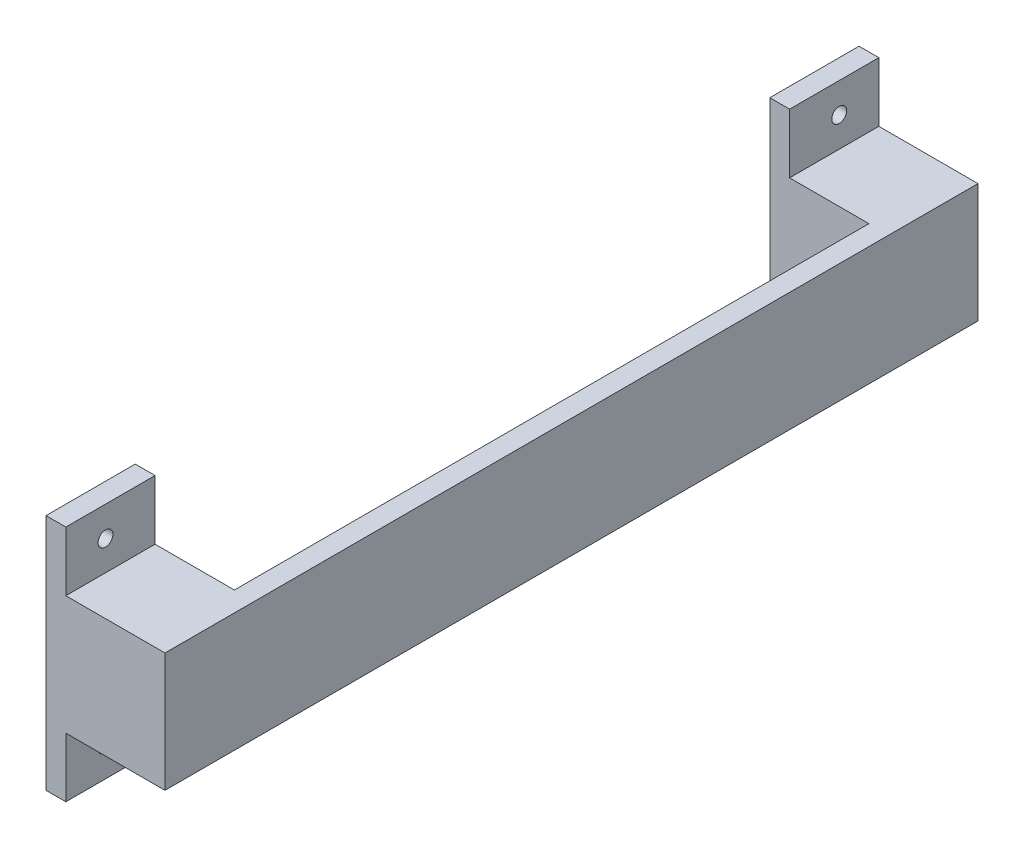
from build123d import *

# Parameters (mm, degrees)
SKETCH1_W           = 130.175
SKETCH1_H           = 19.05
BOSS_EXTRUDE1_DEPTH = 19.05
SKETCH2_W           = 3.175
SKETCH2_H           = 38.1
BOSS_EXTRUDE2_DEPTH = 130.175
SKETCH4_R           = 1.190625
CUT_EXTRUDE1_DEPTH  = 4.175
SKETCH5_W           = 15.875
SKETCH5_H           = 101.6
CUT_EXTRUDE2_DEPTH  = 39.1


with BuildPart() as part:
    # Sketch1 → Boss-Extrude1 (new body)
    with BuildSketch(Plane(origin=(0, 0, 0), x_dir=(0, 0, -1), z_dir=(1, 0, 0))):
        Rectangle(SKETCH1_W, SKETCH1_H)
    extrude(amount=BOSS_EXTRUDE1_DEPTH)

    # Sketch2 → Boss-Extrude2 (add)
    with BuildSketch(Plane.XY.offset(65.0875)):
        with Locations((1.5875, 0)):
            Rectangle(SKETCH2_W, SKETCH2_H)
    extrude(amount=-BOSS_EXTRUDE2_DEPTH)

    # Sketch4 → Cut-Extrude1 (cut, through all)
    with BuildSketch(Plane(origin=(3.175, 0, 0), x_dir=(0, 0, -1), z_dir=(1, 0, 0))):
        with Locations((-58.7375, -14.2875)):
            Circle(SKETCH4_R)
        with Locations((58.7375, -14.2875)):
            Circle(SKETCH4_R)
        with Locations((58.7375, 14.2875)):
            Circle(SKETCH4_R)
        with Locations((-58.7375, 14.2875)):
            Circle(SKETCH4_R)
    extrude(amount=-CUT_EXTRUDE1_DEPTH, mode=Mode.SUBTRACT)

    # Sketch5 → Cut-Extrude2 (cut, through all)
    with BuildSketch(Plane(origin=(0, -19.05, 0), x_dir=(-1, 0, 0), z_dir=(0, -1, 0))):
        with Locations((-7.9375, 0)):
            Rectangle(SKETCH5_W, SKETCH5_H)
    extrude(amount=-CUT_EXTRUDE2_DEPTH, mode=Mode.SUBTRACT)


solid = part.part
